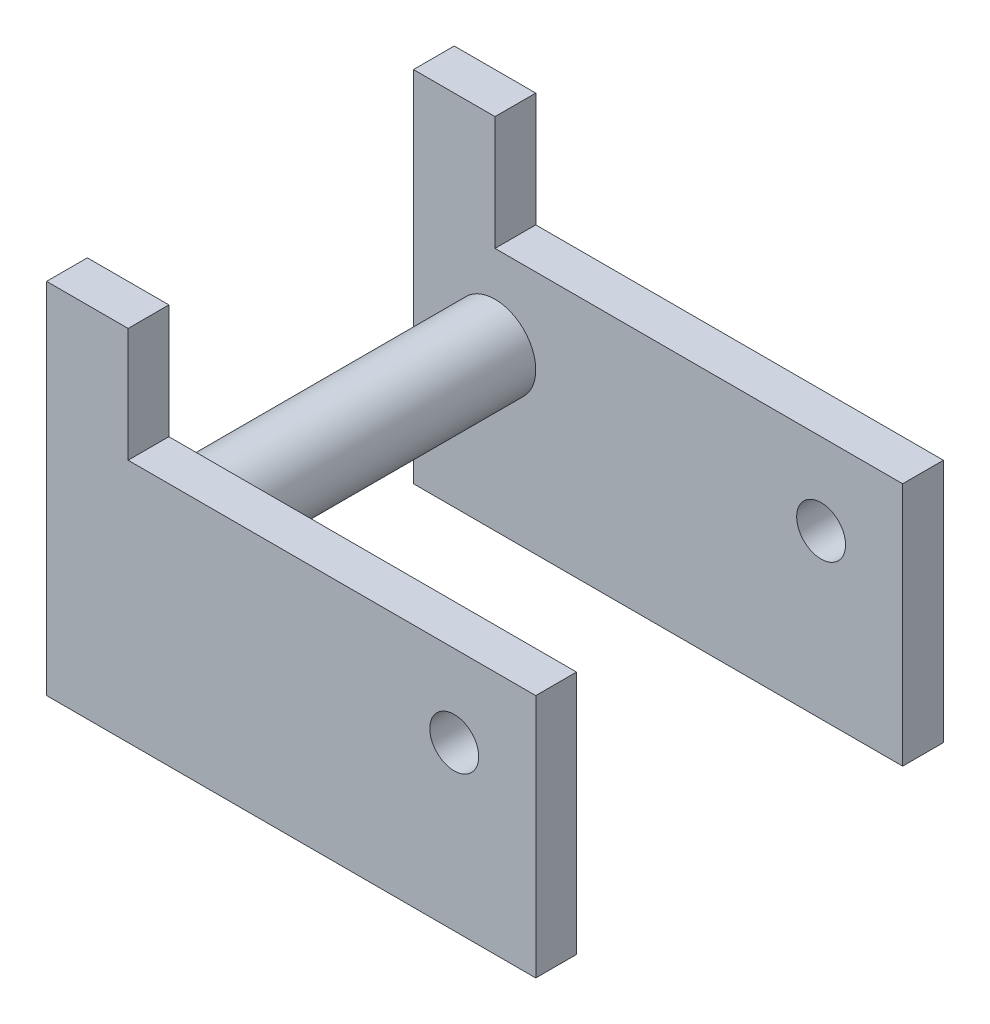
from build123d import *

# Parameters (mm, degrees)
BOSS_EXTRUDE1_DEPTH = 31.75
SKETCH2_W           = 38.1
SKETCH2_H           = 25.4
CUT_EXTRUDE1_DEPTH  = 27.94
SKETCH3_R           = 3.175
BOSS_EXTRUDE2_DEPTH = 25.4
SKETCH5_R           = 1.905
CUT_EXTRUDE2_DEPTH  = 32.75


with BuildPart() as part:
    # Sketch1 → Boss-Extrude1 (new body)
    with BuildSketch(Plane.XY):
        Polygon((0, 0), (-38.1, 0), (-38.1, 6.35), (-38.1, 27.94), (-31.75, 27.94), (-31.75, 19.05), (0, 19.05), align=None)
    extrude(amount=BOSS_EXTRUDE1_DEPTH)

    # Sketch2 → Cut-Extrude1 (cut)
    with BuildSketch(Plane(origin=(0, 27.94, 0), x_dir=(1, 0, 0), z_dir=(0, 1, 0))):
        with Locations((-19.05, -15.875)):
            Rectangle(SKETCH2_W, SKETCH2_H)
    extrude(amount=-CUT_EXTRUDE1_DEPTH, mode=Mode.SUBTRACT)

    # Sketch3 → Boss-Extrude2 (add)
    with BuildSketch(Plane.XY.offset(3.175)):
        with Locations((-31.75, 12.446)):
            Circle(SKETCH3_R)
    extrude(amount=BOSS_EXTRUDE2_DEPTH)

    # Sketch5 → Cut-Extrude2 (cut, through all)
    with BuildSketch(Plane.XY.offset(31.75)):
        with Locations((-6.35, 12.7)):
            Circle(SKETCH5_R)
    extrude(amount=-CUT_EXTRUDE2_DEPTH, mode=Mode.SUBTRACT)


solid = part.part
